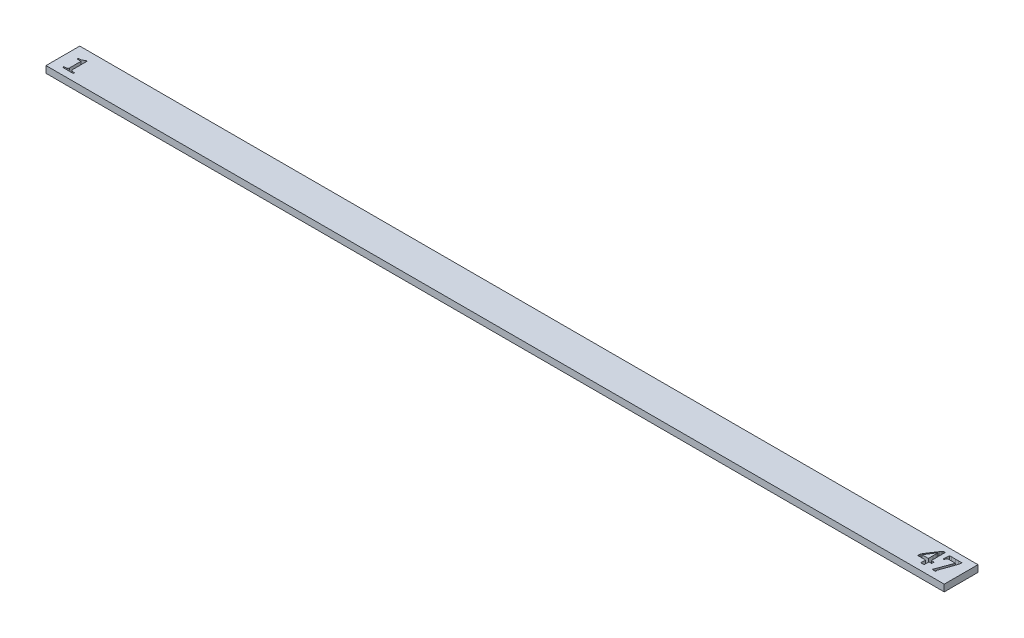
from build123d import *

# Parameters (mm, degrees)
SKETCH1_W               = 399
SKETCH1_H               = 15
BOSS_EXTRUDE1_DEPTH     = 3
CUT_EXTRUDE3_DEPTH      = 3
CUT_EXTRUDE4_DEPTH      = 400.293125515
CUT_EXTRUDE4_DEPTH_BACK = 400.293125515


with BuildPart() as part:
    # Sketch1 → Boss-Extrude1 (new body)
    with BuildSketch(Plane(origin=(0, 0, 0), x_dir=(1, 0, 0), z_dir=(0, 1, 0))):
        with Locations((199.5, 7.5)):
            Rectangle(SKETCH1_W, SKETCH1_H)
    extrude(amount=BOSS_EXTRUDE1_DEPTH)

    # Sketch6 → Cut-Extrude3 (cut)
    with BuildSketch(Plane(origin=(0, 3, 0), x_dir=(1, 0, 0), z_dir=(0, 1, 0))):
        with BuildLine():
            Line((9.066666667, 3), (4.4, 3))
            Line((4.4, 3), (4.4, 3.533333333))
            add(Edge.make_bspline(
                [(4.4, 3.533333333), (4.490588794, 3.537271225), (4.640939574, 3.554398669), (4.861223058, 3.573162067), (5.060458421, 3.593917618), (5.257445963, 3.613512622), (5.464614035, 3.645285276), (5.602979352, 3.665934489), (5.68125, 3.689583333)],
                knots=[0, 0, 0, 0, 0.2103903, 0.351266804, 0.513317769, 0.675537116, 0.81076344, 1, 1, 1, 1], degree=3))
            add(Edge.make_bspline(
                [(5.68125, 3.689583333), (5.748875075, 3.713315135), (5.846065039, 3.75657282), (5.954177233, 3.84358762), (6.019880095, 3.92035001), (6.074718504, 4.012338083), (6.121751402, 4.174441728), (6.136210364, 4.307279756), (6.133333333, 4.402083333)],
                knots=[0, 0, 0, 0, 0.235250595, 0.343488261, 0.45143933, 0.564460817, 0.690934998, 1, 1, 1, 1], degree=3))
            Line((6.133333333, 4.402083333), (6.133333333, 9.4))
            Line((6.133333333, 9.4), (4.4, 9.4))
            Line((4.4, 9.4), (4.4, 9.933333333))
            Line((4.4, 9.933333333), (4.770833333, 9.933333333))
            add(Edge.make_bspline(
                [(4.770833333, 9.933333333), (5.003253924, 9.932619455), (5.34569499, 9.96889158), (5.780241549, 10.092243553), (6.074213986, 10.222394513), (6.33996875, 10.370119885), (6.630202894, 10.569224178), (6.814157432, 10.739590824), (6.90625, 10.866666667)],
                knots=[0, 0, 0, 0, 0.289649108, 0.426683234, 0.561657866, 0.689592667, 0.805376187, 1, 1, 1, 1], degree=3))
            Line((6.90625, 10.866666667), (7.466666667, 10.866666667))
            add(Edge.make_bspline(
                [(7.466666667, 10.866666667), (7.466666667, 10.7), (7.466666667, 10.440277778), (7.466666667, 10.080555556), (7.466666667, 9.51875), (7.466666667, 9.05), (7.466666667, 8.68125)],
                knots=[0, 0, 0, 0, 0.228789323, 0.356530029, 0.493803622, 1, 1, 1, 1], degree=3))
            Line((7.466666667, 8.68125), (7.466666667, 4.477083333))
            add(Edge.make_bspline(
                [(7.466666667, 4.477083333), (7.465171299, 4.323802417), (7.508915415, 4.1322322), (7.627640514, 3.94057428), (7.725471426, 3.836074847), (7.81353907, 3.774674671), (7.879166667, 3.745833333)],
                knots=[0, 0, 0, 0, 0.518335827, 0.640811583, 0.758815486, 1, 1, 1, 1], degree=3))
            add(Edge.make_bspline(
                [(7.879166667, 3.745833333), (7.9542548, 3.71328483), (8.086144111, 3.677803773), (8.281176448, 3.634356203), (8.460811746, 3.603704136), (8.641304858, 3.575188457), (8.843360346, 3.550303966), (8.982249303, 3.535230482), (9.066666667, 3.533333333)],
                knots=[0, 0, 0, 0, 0.202205355, 0.337957571, 0.495327151, 0.653832039, 0.790920356, 1, 1, 1, 1], degree=3))
            Line((9.066666667, 3.533333333), (9.066666667, 3))
        make_face()
    extrude(amount=-CUT_EXTRUDE3_DEPTH, mode=Mode.SUBTRACT)

    # Sketch3 → Cut-Extrude4 (cut, two sides)
    with BuildSketch(Plane(origin=(0, 3, 0), x_dir=(1, 0, 0), z_dir=(0, 1, 0))) as cut_extrude4_sk:
        with BuildLine():
            Line((385.567164179, 5.012826493), (385.567164179, 3))
            Line((385.567164179, 3), (387.044776119, 3))
            add(Edge.make_bspline(
                [(387.044776119, 3), (387.044776119, 3.023087687), (387.044776119, 3.219682836), (387.044776119, 3.466651119), (387.044776119, 3.690531716), (387.044776119, 3.740904851)],
                knots=[0, 0, 0, 0, 0.119565217, 1.018115942, 1.278985507, 1.278985507, 1.278985507, 1.278985507], degree=3))
            Line((387.044776119, 3.740904851), (387.044776119, 4.941464552))
            add(Edge.make_bspline(
                [(387.044776119, 5.149253731), (387.044776119, 5.103078358), (387.044776119, 5.033815299), (387.044776119, 4.964552239), (387.044776119, 4.941464552)],
                knots=[0, 0, 0, 0, 0.666666667, 1, 1, 1, 1], degree=3))
            add(Edge.make_bspline(
                [(387.044776119, 5.149253731), (387.325326493, 5.149253731), (387.728311567, 5.149253731), (388.131296642, 5.149253731), (388.253731343, 5.149253731)],
                knots=[0, 0, 0, 0, 1.496268657, 2.149253731, 2.149253731, 2.149253731, 2.149253731], degree=3))
            Line((388.253731343, 5.149253731), (388.253731343, 6.223880597))
            add(Edge.make_bspline(
                [(387.888526119, 6.223880597), (388.071128731, 6.223880597), (388.253731343, 6.223880597)],
                knots=[0, 0, 0, 1, 1, 1], degree=2))
            Line((387.888526119, 6.223880597), (387.705923507, 6.223880597))
            add(Edge.make_bspline(
                [(387.044776119, 6.223880597), (387.375349813, 6.223880597), (387.705923507, 6.223880597)],
                knots=[0, 0, 0, 1, 1, 1], degree=2))
            Line((387.044776119, 6.223880597), (387.044776119, 12.381996269))
            add(Edge.make_bspline(
                [(386.572527985, 12.402985075), (386.632647323, 12.400207034), (386.790437013, 12.4025118), (386.947312533, 12.38301176), (387.044776119, 12.381996269)],
                knots=[0, 0, 0, 0, 0.381893514, 1, 1, 1, 1], degree=3))
            add(Edge.make_bspline(
                [(386.081389925, 12.381996269), (386.187973018, 12.382177604), (386.351160041, 12.402008298), (386.515204614, 12.400139253), (386.572527985, 12.402985075)],
                knots=[0, 0, 0, 0, 0.649820797, 1, 1, 1, 1], degree=3))
            add(Edge.make_bspline(
                [(385.800139925, 11.981110075), (385.858943812, 12.063224967), (385.961858879, 12.190417263), (386.050113092, 12.328105409), (386.081389925, 12.381996269)],
                knots=[0, 0, 0, 0, 0.61851227, 1, 1, 1, 1], degree=3))
            add(Edge.make_bspline(
                [(385.455923507, 11.464785448), (385.518372607, 11.562095513), (385.621998043, 11.741678016), (385.746076675, 11.907653743), (385.800139925, 11.981110075)],
                knots=[0, 0, 0, 0, 0.55903442, 1, 1, 1, 1], degree=3))
            add(Edge.make_bspline(
                [(384.150419776, 9.559001866), (384.307055602, 9.806282448), (384.53909514, 10.144078632), (384.824760311, 10.565502776), (385.002153351, 10.807634783), (385.150609206, 11.013917219), (385.303139644, 11.22584384), (385.400401458, 11.374305928), (385.455923507, 11.464785448)],
                knots=[0, 0, 0, 0, 0.379956122, 0.532152195, 0.660988778, 0.769655013, 0.862163026, 1, 1, 1, 1], degree=3))
            Line((384.150419776, 9.559001866), (382.494402985, 6.998367537))
            add(Edge.make_bspline(
                [(382.074626866, 6.137826493), (382.123782796, 6.244403893), (382.193615111, 6.39626409), (382.286162448, 6.585468576), (382.342247315, 6.702586567), (382.390429815, 6.801289218), (382.439191492, 6.898328094), (382.471418955, 6.962783636), (382.494402985, 6.998367537)],
                knots=[0, 0, 0, 0, 0.367667449, 0.523514139, 0.659760796, 0.774435554, 0.867544135, 1, 1, 1, 1], degree=3))
            Line((382.074626866, 6.137826493), (382.074626866, 5.149253731))
            add(Edge.make_bspline(
                [(382.074626866, 5.149253731), (382.222248134, 5.149253731), (382.886893657, 5.149253731), (383.551539179, 5.149253731), (384.068563433, 5.149253731)],
                knots=[0, 0, 0, 0, 1.343949045, 6.050955414, 6.050955414, 6.050955414, 6.050955414], degree=3))
            Line((384.068563433, 5.149253731), (384.540811567, 5.149253731))
            add(Edge.make_bspline(
                [(385.567164179, 5.149253731), (385.424440299, 5.149253731), (385.082322761, 5.149253731), (384.740205224, 5.149253731), (384.540811567, 5.149253731)],
                knots=[0, 0, 0, 0, 0.417177914, 1, 1, 1, 1], degree=3))
            add(Edge.make_bspline(
                [(385.567164179, 5.012826493), (385.567164179, 5.081040112), (385.567164179, 5.149253731)],
                knots=[0, 0, 0, 1, 1, 1], degree=2))
        make_face()
        with BuildLine():
            Line((385.567164179, 8.480177239), (385.567164179, 7.43073694))
            add(Edge.make_bspline(
                [(385.567164179, 7.43073694), (385.567164179, 7.399253731), (385.567164179, 7.343283582), (385.567164179, 7.257229478), (385.567164179, 7.036847015), (385.567164179, 6.735307836), (385.567164179, 6.463852612), (385.567164179, 6.358208955)],
                knots=[0, 0, 0, 0, 0.178571429, 0.317460317, 0.488095238, 1.428571429, 2.027777778, 2.027777778, 2.027777778, 2.027777778], degree=3))
            Line((385.567164179, 6.358208955), (383.128264925, 6.358208955))
            add(Edge.make_bspline(
                [(382.830223881, 6.358208955), (382.891791045, 6.358208955), (382.99113806, 6.358208955), (383.090485075, 6.358208955), (383.128264925, 6.358208955)],
                knots=[0, 0, 0, 0, 0.61971831, 1, 1, 1, 1], degree=3))
            add(Edge.make_bspline(
                [(383.74113806, 7.894589552), (383.591296084, 7.647321822), (383.262215539, 7.150814848), (382.95540342, 6.639149775), (382.830223881, 6.358208955)],
                knots=[0, 0, 0, 0, 0.485063777, 1, 1, 1, 1], degree=3))
            add(Edge.make_bspline(
                [(383.948927239, 8.234608209), (383.841452073, 8.066790517), (383.74113806, 7.894589552)],
                knots=[0, 0, 0, 1, 1, 1], degree=2))
            Line((383.948927239, 8.234608209), (384.593283582, 9.277751866))
            add(Edge.make_bspline(
                [(385.216651119, 10.13829291), (385.114918684, 10.011248227), (384.900543107, 9.729031505), (384.699117887, 9.437421574), (384.593283582, 9.277751866)],
                knots=[0, 0, 0, 0, 0.459339067, 1, 1, 1, 1], degree=3))
            add(Edge.make_bspline(
                [(385.380363806, 10.385960821), (385.30628152, 10.256935511), (385.216651119, 10.13829291)],
                knots=[0, 0, 0, 1, 1, 1], degree=2))
            add(Edge.make_bspline(
                [(385.581856343, 10.646222015), (385.487918553, 10.510875926), (385.380363806, 10.385960821)],
                knots=[0, 0, 0, 1, 1, 1], degree=2))
            add(Edge.make_bspline(
                [(385.567164179, 10.306203358), (385.565373822, 10.346876212), (385.575433631, 10.460028929), (385.576017407, 10.573560777), (385.581856343, 10.646222015)],
                knots=[0, 0, 0, 0, 0.357983602, 1, 1, 1, 1], degree=3))
            Line((385.567164179, 10.306203358), (385.573460821, 9.733208955))
            Line((385.573460821, 9.733208955), (385.567164179, 8.480177239))
        make_face(mode=Mode.SUBTRACT)
        with BuildLine():
            add(Edge.make_bspline(
                [(390.604780715, 3), (390.609477334, 3.013329088), (390.674102629, 3.191948165), (390.752282772, 3.364778234), (390.824860075, 3.524720149)],
                knots=[0.327738881, 0.327738881, 0.327738881, 0.327738881, 0.377761085, 1, 1, 1, 1], degree=3))
            Line((390.604780715, 3), (392.282510903, 3))
            add(Edge.make_bspline(
                [(392.28358209, 3.016791045), (392.283441048, 3.011157102), (392.283079462, 3.005558782), (392.282510903, 3)],
                knots=[0, 0, 0, 0, 0.047372749, 0.047372749, 0.047372749, 0.047372749], degree=3))
            add(Edge.make_bspline(
                [(391.958255597, 3.459654851), (391.959359318, 3.418786808), (391.983917308, 3.355260387), (392.051474188, 3.28641717), (392.119265243, 3.234969283), (392.18890107, 3.185275189), (392.256975495, 3.118645064), (392.282530612, 3.05647035), (392.28358209, 3.016791045)],
                knots=[0, 0, 0, 0, 0.213120215, 0.343422421, 0.503306522, 0.66092689, 0.793754467, 1, 1, 1, 1], degree=3))
            add(Edge.make_bspline(
                [(392.031716418, 3.703125), (391.970792091, 3.588260157), (391.958255597, 3.459654851)],
                knots=[0, 0, 0, 1, 1, 1], degree=2))
            Line((392.031716418, 3.703125), (392.604710821, 5.31926306))
            add(Edge.make_bspline(
                [(392.940531716, 6.251166045), (392.901867219, 6.128988579), (392.789271875, 5.818532343), (392.677344913, 5.507885229), (392.604710821, 5.31926306)],
                knots=[0, 0, 0, 0, 0.387977624, 1, 1, 1, 1], degree=3))
            Line((392.940531716, 6.251166045), (393.291044776, 7.248134328))
            add(Edge.make_bspline(
                [(393.561800373, 7.976445896), (393.515781111, 7.867199658), (393.42613119, 7.624150454), (393.336545299, 7.38111444), (393.291044776, 7.248134328)],
                knots=[0, 0, 0, 0, 0.457478678, 1, 1, 1, 1], degree=3))
            add(Edge.make_bspline(
                [(393.876632463, 8.885261194), (393.813898269, 8.723451669), (393.704868261, 8.421855137), (393.603802997, 8.117485745), (393.561800373, 7.976445896)],
                knots=[0, 0, 0, 0, 0.541149528, 1, 1, 1, 1], degree=3))
            add(Edge.make_bspline(
                [(394.506296642, 10.749067164), (394.371316102, 10.385817027), (394.222590265, 9.935527531), (394.055047554, 9.414875731), (393.973187852, 9.159276866), (393.914575292, 8.9873101), (393.876632463, 8.885261194)],
                knots=[0, 0, 0, 0, 0.59075753, 0.723007296, 0.834001471, 1, 1, 1, 1], degree=3))
            add(Edge.make_bspline(
                [(394.701492537, 11.714552239), (394.703131347, 11.668589183), (394.69068364, 11.591838207), (394.674063032, 11.47775602), (394.652159642, 11.365919222), (394.62514035, 11.236424374), (394.577258352, 11.028335682), (394.535714677, 10.864320831), (394.506296642, 10.749067164)],
                knots=[0, 0, 0, 0, 0.13905043, 0.235945899, 0.350700723, 0.485483275, 0.63825942, 1, 1, 1, 1], degree=3))
            add(Edge.make_bspline(
                [(394.680503731, 12.134328358), (394.701575998, 11.924942161), (394.701492537, 11.714552239)],
                knots=[0, 0, 0, 1, 1, 1], degree=2))
            add(Edge.make_bspline(
                [(394.416044776, 12.134328358), (394.548274254, 12.134328358), (394.680503731, 12.134328358)],
                knots=[0, 0, 0, 1, 1, 1], degree=2))
            Line((394.416044776, 12.134328358), (393.30363806, 12.134328358))
            Line((393.30363806, 12.134328358), (391.86170709, 12.119636194))
            Line((391.86170709, 12.119636194), (390.157416045, 12.134328358))
            add(Edge.make_bspline(
                [(389.288479478, 12.134328358), (389.407416045, 12.134328358), (389.697061567, 12.134328358), (389.98670709, 12.134328358), (390.157416045, 12.134328358)],
                knots=[0, 0, 0, 0, 0.410628019, 1, 1, 1, 1], degree=3))
            add(Edge.make_bspline(
                [(389.139458955, 10.812033582), (389.174306511, 11.049653107), (389.21198534, 11.491672506), (389.256641484, 11.933109174), (389.288479478, 12.134328358)],
                knots=[0, 0, 0, 0, 0.541004894, 1, 1, 1, 1], degree=3))
            add(Edge.make_bspline(
                [(389.059701493, 9.733208955), (389.057663158, 9.882622623), (389.085872177, 10.242409551), (389.112263822, 10.602114141), (389.139458955, 10.812033582)],
                knots=[0, 0, 0, 0, 0.413664263, 1, 1, 1, 1], degree=3))
            add(Edge.make_bspline(
                [(389.269589552, 9.447761194), (389.209575572, 9.444087607), (389.072553162, 9.510974529), (389.061202473, 9.664537833), (389.059701493, 9.733208955)],
                knots=[0, 0, 0, 0, 0.447088882, 1, 1, 1, 1], degree=3))
            add(Edge.make_bspline(
                [(390.390391791, 10.52238806), (390.279523901, 10.519107819), (390.123281613, 10.516165209), (389.943939678, 10.457590251), (389.847926059, 10.402046043), (389.780071966, 10.318527079), (389.725882193, 10.21568689), (389.682311943, 10.088092188), (389.653666964, 9.944727335), (389.627648786, 9.805193063), (389.598045358, 9.686069457), (389.562105015, 9.598330089), (389.527739987, 9.531559532), (389.476868027, 9.493930387), (389.395857316, 9.451249493), (389.319667629, 9.45247622), (389.269589552, 9.447761194)],
                knots=[0, 0, 0, 0, 0.189212858, 0.259177039, 0.317618741, 0.37382617, 0.438411826, 0.513621268, 0.600883716, 0.685342077, 0.753932297, 0.80753941, 0.846294416, 0.878260495, 0.912652405, 1, 1, 1, 1], degree=3))
            Line((390.390391791, 10.52238806), (391.234141791, 10.505597015))
            Line((391.234141791, 10.505597015), (392.289878731, 10.52238806))
            add(Edge.make_bspline(
                [(393.416977612, 10.482509328), (393.207169462, 10.494052768), (392.831609443, 10.511600567), (392.45577418, 10.523472847), (392.289878731, 10.52238806)],
                knots=[0, 0, 0, 0, 0.558858828, 1, 1, 1, 1], degree=3))
            add(Edge.make_bspline(
                [(393.282649254, 10.104710821), (393.296446887, 10.155676607), (393.348863125, 10.278905641), (393.384307376, 10.408166699), (393.416977612, 10.482509328)],
                knots=[0, 0, 0, 0, 0.394055214, 1, 1, 1, 1], degree=3))
            add(Edge.make_bspline(
                [(393.079057836, 9.559001866), (393.116057825, 9.635348826), (393.185585318, 9.816861246), (393.249296629, 10.000359879), (393.282649254, 10.104710821)],
                knots=[0, 0, 0, 0, 0.436195377, 1, 1, 1, 1], degree=3))
            Line((393.079057836, 9.559001866), (392.764225746, 8.69426306))
            Line((392.764225746, 8.69426306), (391.506996269, 5.304570896))
            add(Edge.make_bspline(
                [(390.824860075, 3.524720149), (390.859194022, 3.604153438), (390.916976822, 3.739859696), (390.997461012, 3.945705724), (391.076766977, 4.150868746), (391.169922308, 4.390270462), (391.314377186, 4.778720373), (391.426619167, 5.087912153), (391.506996269, 5.304570896)],
                knots=[0, 0, 0, 0, 0.136189941, 0.232079304, 0.347806246, 0.482346311, 0.636338705, 1, 1, 1, 1], degree=3))
        make_face()
    extrude(amount=CUT_EXTRUDE4_DEPTH, mode=Mode.SUBTRACT)
    extrude(cut_extrude4_sk.sketch, amount=-CUT_EXTRUDE4_DEPTH_BACK, mode=Mode.SUBTRACT)


with BuildPart() as cut_extrude4_piece_1:
    # of the separate pieces the step leaves, piece 1, a body of its own (cut_extrude4_pieces)
    add(part.part.solids().sort_by_distance((0, 0, 0))[0])


with BuildPart() as cut_extrude4_piece_2:
    # of the separate pieces the step leaves, piece 2, a body of its own (cut_extrude4_pieces)
    add(part.part.solids().sort_by_distance((384.593283582, 0, -9.277751866))[0])


solid = Compound([cut_extrude4_piece_1.part, cut_extrude4_piece_2.part])
